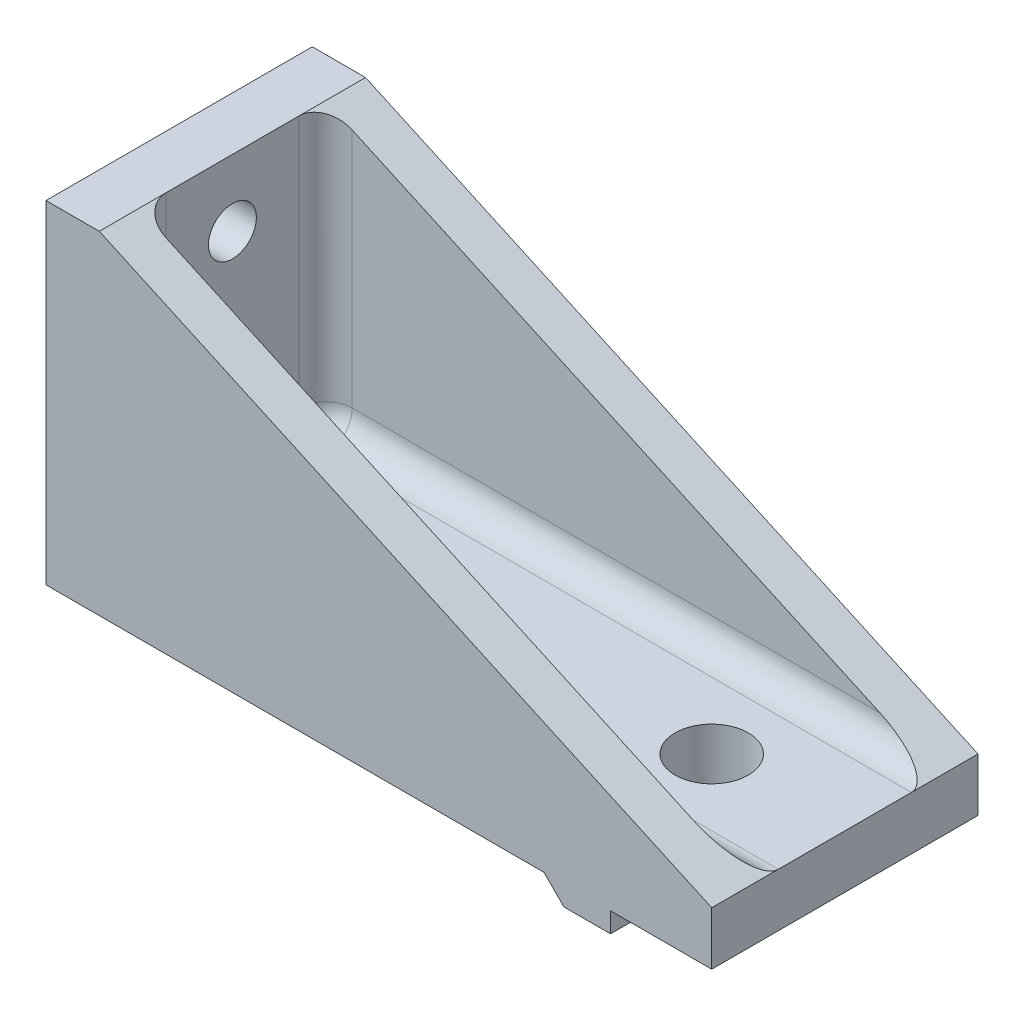
from build123d import *

# Parameters (mm, degrees)
SALIENTE_EXTRUIR1_DEPTH = 10
CROQUIS7_W              = 6
CROQUIS7_H              = 1.5
CORTAR_EXTRUIR3_DEPTH   = 51
CROQUIS3_R              = 2.75
CORTAR_EXTRUIR1_DEPTH   = 20
CROQUIS4_R              = 1.8
CORTAR_EXTRUIR2_DEPTH   = 20
SALIENTE_EXTRUIR2_DEPTH = 3
REDONDEO1_R             = 2


with BuildPart() as part:
    # Croquis1 → Saliente-Extruir1 (new body, symmetric)
    with BuildSketch(Plane.XY):
        Polygon((0, 0), (37.4, 0), (38.9, -1.5), (42.4, -1.5), (42.4, 0), (50, 0), (50, 4), (4, 4), (4, 25), (0, 25), align=None)
    extrude(amount=SALIENTE_EXTRUIR1_DEPTH, both=True)

    # Croquis7 → Cortar-Extruir3 (cut, through all)
    with BuildSketch(Plane(origin=(50, 0, 0), x_dir=(0, 0, -1), z_dir=(1, 0, 0))):
        with Locations((0, -0.75)):
            Rectangle(CROQUIS7_W, CROQUIS7_H)
    extrude(amount=-CORTAR_EXTRUIR3_DEPTH, mode=Mode.SUBTRACT)

    # Croquis3 → Cortar-Extruir1 (cut)
    with BuildSketch(Plane.XZ):
        with Locations((40, 0)):
            Circle(CROQUIS3_R)
    extrude(amount=-CORTAR_EXTRUIR1_DEPTH, mode=Mode.SUBTRACT)

    # Croquis4 → Cortar-Extruir2 (cut)
    with BuildSketch(Plane(origin=(4, 0, 0), x_dir=(0, 0, -1), z_dir=(1, 0, 0))):
        with Locations((0, 20)):
            Circle(CROQUIS4_R)
        with Locations((0, 10)):
            Circle(CROQUIS4_R)
    extrude(amount=-CORTAR_EXTRUIR2_DEPTH, mode=Mode.SUBTRACT)

    # Croquis5 → Saliente-Extruir2 (add)
    with BuildSketch(Plane(origin=(0, 0, -10), x_dir=(-1, 0, 0), z_dir=(0, 0, -1))):
        Polygon((0, 0), (-50, 0), (-50, 4), (-4, 25), (0, 25), align=None)
    saliente_extruir2 = extrude(amount=-SALIENTE_EXTRUIR2_DEPTH)

    # Simetría1: Saliente-Extruir2 across plane
    add(saliente_extruir2.mirror(Plane.XY))

    # Redondeo1
    redondeo1_edges = [part.edges().sort_by_distance(p)[0] for p in [
        (4, 14.5, 7),
        (27, 4, 7),
        (27, 4, -7),
        (4, 14.5, -7),
        (4, 4, 0),
    ]]
    fillet(redondeo1_edges, radius=REDONDEO1_R)


solid = part.part
